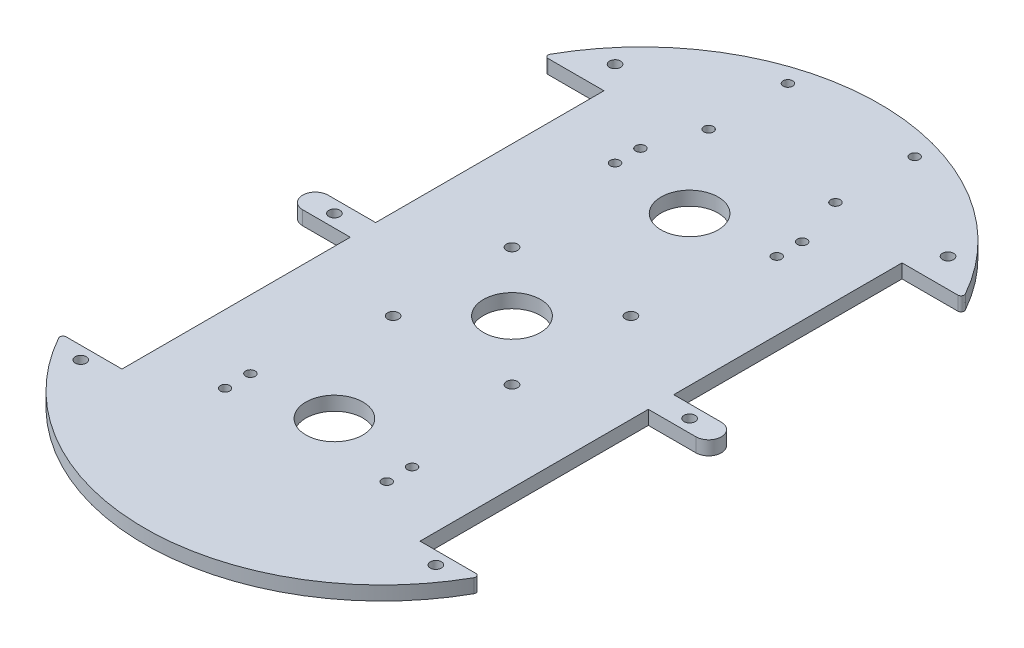
from build123d import *

# Parameters (mm, degrees)
SKETCH2_W                  = 132
SKETCH2_H                  = 232
PLATE_SIZE_DEPTH           = 4.4
SKETCH4_OUTSIDE_W          = 187.392
SKETCH4_OUTSIDE_H          = 287.392
OUTER_PROFILE_DEPTH        = 5.4
M3_CLEARANCE_HOLE1_D       = 3.5
F_18_0_18_DIAMETER_HOLE4_D = 18
M3_CLEARANCE_HOLE2_D       = 3.5
M3_CLEARANCE_HOLE3_D       = 3
M3_CLEARANCE_HOLE4_D       = 3
SKETCH17_R                 = 9.017
CUT_EXTRUDE1_DEPTH         = 53.34


with BuildPart() as part:
    # Sketch2 → Plate Size (new body)
    with BuildSketch(Plane(origin=(0, 0, 0), x_dir=(1, 0, 0), z_dir=(0, 1, 0))):
        Rectangle(SKETCH2_W, SKETCH2_H)
    extrude(amount=PLATE_SIZE_DEPTH)

    # Sketch4 outside → Outer Profile (cut, through all)
    with BuildSketch(Plane(origin=(0, 0, 0), x_dir=(1, 0, 0), z_dir=(0, 1, 0))):
        Rectangle(SKETCH4_OUTSIDE_W, SKETCH4_OUTSIDE_H)
        with BuildLine():
            Line((-64.599996007, 76), (-47, 76))
            Line((-47, 76), (-47, 4))
            Line((-47, 4), (-62, 4))
            ThreePointArc((-62, 4), (-66, 0), (-62, -4))
            Line((-62, -4), (-47, -4))
            Line((-47, -4), (-47, -76))
            Line((-47, -76), (-64.599996007, -76))
            ThreePointArc((-64.599996007, -76), (-65.462483305, -76.493921289), (-65.472968926, -77.487768677))
            ThreePointArc((-65.472968926, -77.487768677), (0, -115.905117871), (65.472968926, -77.487768677))
            ThreePointArc((65.472968926, -77.487768677), (65.462483305, -76.493921289), (64.599996007, -76))
            Line((64.599996007, -76), (47, -76))
            Line((47, -76), (47, -4))
            Line((47, -4), (62, -4))
            ThreePointArc((62, -4), (66, 0), (62, 4))
            Line((62, 4), (47, 4))
            Line((47, 4), (47, 76))
            Line((47, 76), (64.599996007, 76))
            ThreePointArc((64.599996007, 76), (65.462483305, 76.493921289), (65.472968926, 77.487768677))
            ThreePointArc((65.472968926, 77.487768677), (0, 115.905117871), (-65.472968926, 77.487768677))
            ThreePointArc((-65.472968926, 77.487768677), (-65.462483305, 76.493921289), (-64.599996007, 76))
        make_face(mode=Mode.SUBTRACT)
    extrude(amount=OUTER_PROFILE_DEPTH, mode=Mode.SUBTRACT)

    # M3 Clearance Hole1 (through all)
    with Locations(Plane.XZ):
        with Locations((-55.999996141, 80.000001937), (55.999996141, 80.000001937), (-52.5, -85), (52.5, -85), (-55.999996141, 0), (55.999996141, 0)):
            Hole(M3_CLEARANCE_HOLE1_D / 2)

    # Ø18.0 (18) Diameter Hole4 (through all)
    with Locations(Plane.XZ):
        with Locations((0, -56), (0, 56)):
            Hole(F_18_0_18_DIAMETER_HOLE4_D / 2)

    # M3 Clearance Hole2 (through all)
    with Locations(Plane.XZ):
        with Locations((18.75, -18.75), (-18.75, 18.75), (18.75, 18.75), (-18.75, -18.75)):
            Hole(M3_CLEARANCE_HOLE2_D / 2)

    # M3 Clearance Hole3 (through all)
    with Locations(Plane.XZ):
        with Locations((-25.5, -66.00000008), (25.5, 65.00000008), (-25.5, 65.00000008), (25.5, -66.00000008), (-25.5, -58.00000008), (25.5, -58.00000008), (25.5, 57.00000008), (-25.5, 57.00000008)):
            Hole(M3_CLEARANCE_HOLE3_D / 2)

    # M3 Clearance Hole4 (through all)
    with Locations(Plane.XZ):
        with Locations((-20, -107), (20, -107), (-20, -82), (20, -82)):
            Hole(M3_CLEARANCE_HOLE4_D / 2)

    # Sketch17 → Cut-Extrude1 (cut)
    with BuildSketch(Plane(origin=(0, 4.4, 0), x_dir=(1, 0, 0), z_dir=(0, 1, 0))):
        Circle(SKETCH17_R)
    extrude(amount=-CUT_EXTRUDE1_DEPTH, mode=Mode.SUBTRACT)


solid = part.part
